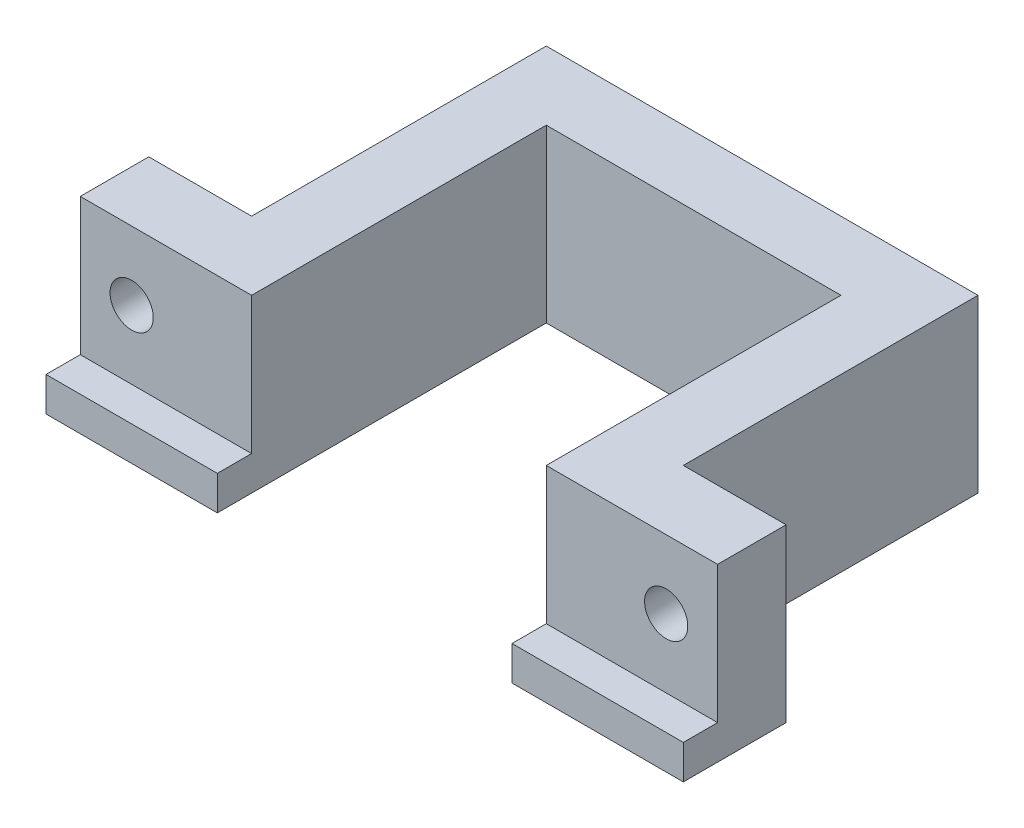
from build123d import *

# Parameters (mm, degrees)
BOSS_EXTRUDE1_DEPTH = 20
SKETCH2_R           = 3.15
CUT_EXTRUDE2_DEPTH  = 11
SKETCH3_R           = 4.25
CUT_EXTRUDE3_DEPTH  = 4
BOSS_EXTRUDE2_DEPTH = 5


with BuildPart() as part:
    # Sketch1 → Boss-Extrude1 (new body)
    with BuildSketch(Plane(origin=(0, 0, 0), x_dir=(1, 0, 0), z_dir=(0, 1, 0))):
        Polygon((0, 0), (0, 43), (43, 43), (43, 0), (68, 0), (68, 10), (53, 10), (53, 53), (-10, 53), (-10, 10), (-25, 10), (-25, 0), align=None)
    extrude(amount=BOSS_EXTRUDE1_DEPTH)

    # Sketch2 → Cut-Extrude2 (cut, through all)
    with BuildSketch(Plane(origin=(0, 0, -10), x_dir=(-1, 0, 0), z_dir=(0, 0, -1))):
        with Locations((-60.5, 10)):
            Circle(SKETCH2_R)
        with Locations((17.5, 10)):
            Circle(SKETCH2_R)
    extrude(amount=-CUT_EXTRUDE2_DEPTH, mode=Mode.SUBTRACT)

    # Sketch3 → Cut-Extrude3 (cut)
    with BuildSketch(Plane(origin=(0, 0, -10), x_dir=(-1, 0, 0), z_dir=(0, 0, -1))):
        with Locations((17.5, 10)):
            Circle(SKETCH3_R)
        with Locations((-60.5, 10)):
            Circle(SKETCH3_R)
    extrude(amount=-CUT_EXTRUDE3_DEPTH, mode=Mode.SUBTRACT)

    # Sketch4 → Boss-Extrude2 (add)
    with BuildSketch(Plane.XZ):
        Polygon((-25, 5), (0, 5), (0, -43), (43, -43), (43, 5), (68, 5), (68, -10), (53, -10), (53, -53), (-10, -53), (-10, -10), (-25, -10), align=None)
    extrude(amount=BOSS_EXTRUDE2_DEPTH)


solid = part.part
